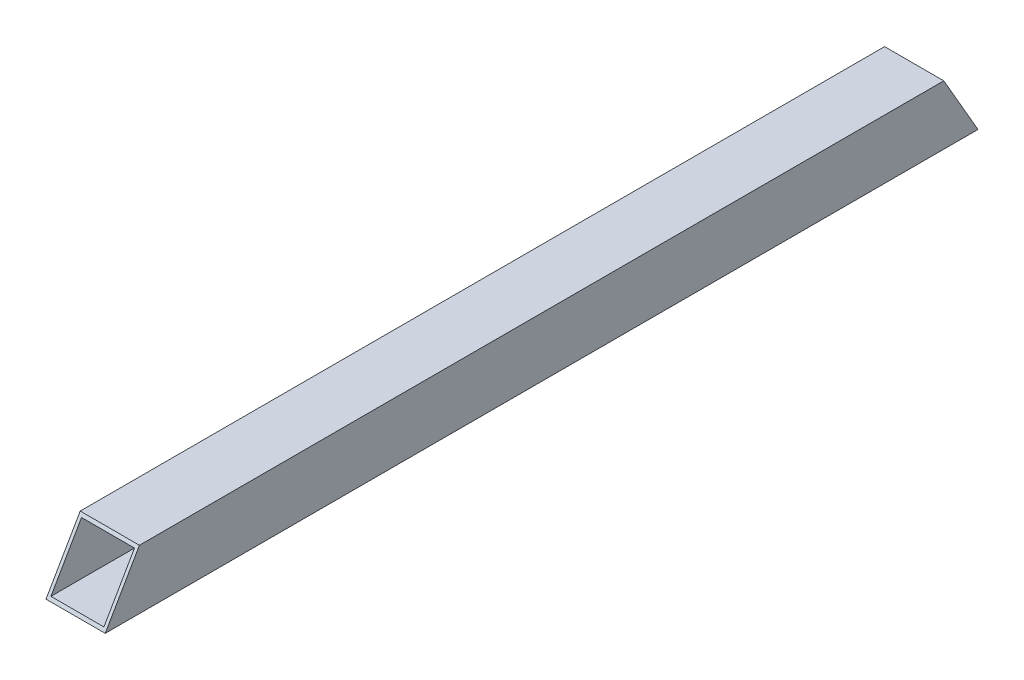
from build123d import *

# Parameters (mm, degrees)
SKETCH1_W               = 19
SKETCH1_H               = 19
SKETCH1_W_2             = 17
SKETCH1_H_2             = 17
BOSS_EXTRUDE1_DEPTH     = 280
CUT_EXTRUDE3_DEPTH      = 1
CUT_EXTRUDE3_DEPTH_BACK = 20
CUT_EXTRUDE4_DEPTH      = 1
CUT_EXTRUDE4_DEPTH_BACK = 20


with BuildPart() as part:
    # Sketch1 → Boss-Extrude1 (new body)
    with BuildSketch(Plane.XY):
        Rectangle(SKETCH1_W, SKETCH1_H)
        Rectangle(SKETCH1_W_2, SKETCH1_H_2, mode=Mode.SUBTRACT)
    extrude(amount=BOSS_EXTRUDE1_DEPTH)

    # Sketch4 → Cut-Extrude3 (cut, two sides)
    with BuildSketch(Plane(origin=(9.5, 0, 0), x_dir=(0, 0, -1), z_dir=(1, 0, 0))) as cut_extrude3_sk:
        Polygon((-565.643902481, -504.24975197), (-280, -9.5), (-269.030344885, 9.5), (16.613557596, 504.24975197), (-972.885946344, 1075.537556933), (-1555.143406422, 67.038052993), align=None)
    extrude(amount=CUT_EXTRUDE3_DEPTH, mode=Mode.SUBTRACT)
    extrude(cut_extrude3_sk.sketch, amount=-CUT_EXTRUDE3_DEPTH_BACK, mode=Mode.SUBTRACT)

    # Sketch5 → Cut-Extrude4 (cut, two sides)
    with BuildSketch(Plane(origin=(9.5, 0, 0), x_dir=(0, 0, -1), z_dir=(1, 0, 0))) as cut_extrude4_sk:
        Polygon((285.643902481, -504.24975197), (0, -9.5), (-10.969655115, 9.5), (-296.613557596, 504.24975197), (692.885946344, 1075.537556933), (1275.143406422, 67.038052993), align=None)
    extrude(amount=CUT_EXTRUDE4_DEPTH, mode=Mode.SUBTRACT)
    extrude(cut_extrude4_sk.sketch, amount=-CUT_EXTRUDE4_DEPTH_BACK, mode=Mode.SUBTRACT)


solid = part.part
